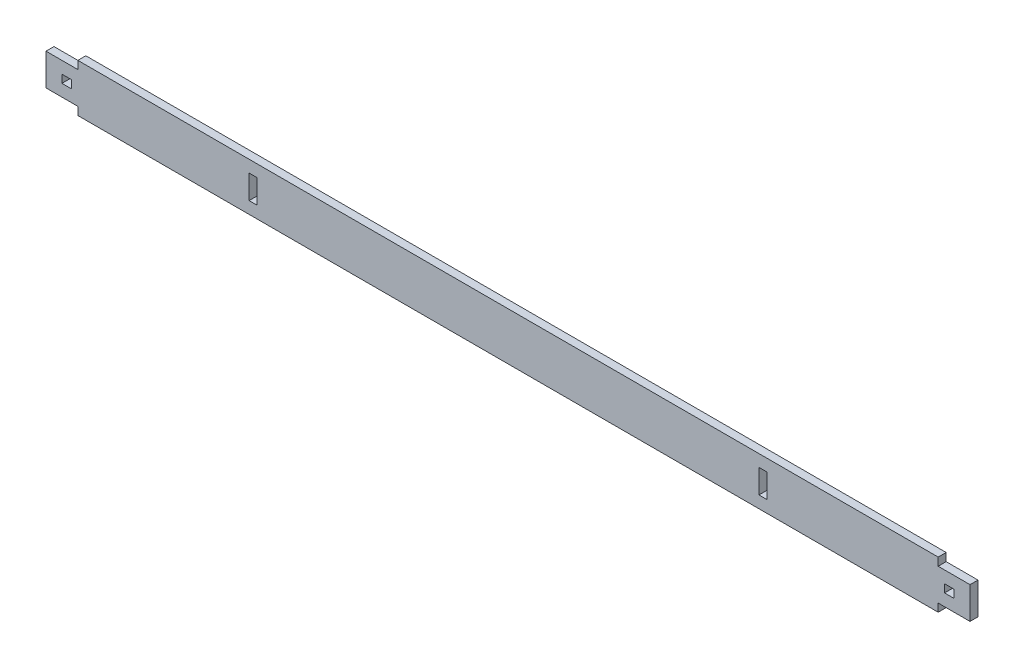
from build123d import *

# Parameters (mm, degrees)
SKETCH1_W           = 685.8
SKETCH1_H           = 38.1
BOSS_EXTRUDE1_DEPTH = 6.35
SKETCH2_W           = 50.8
SKETCH2_H           = 25.4
BOSS_EXTRUDE2_DEPTH = 6.35
SKETCH3_W           = 7.62
SKETCH3_H           = 6.35
CUT_EXTRUDE1_DEPTH  = 7.35
SKETCH4_W           = 6.35
SKETCH4_H           = 19.05
CUT_EXTRUDE2_DEPTH  = 7.35


with BuildPart() as part:
    # Sketch1 → Boss-Extrude1 (new body)
    with BuildSketch(Plane.XY):
        Rectangle(SKETCH1_W, SKETCH1_H)
    extrude(amount=BOSS_EXTRUDE1_DEPTH)

    # Sketch2 → Boss-Extrude2 (add)
    with BuildSketch(Plane.XY.offset(6.35)):
        with Locations((-342.9, 0)):
            Rectangle(SKETCH2_W, SKETCH2_H)
    boss_extrude2 = extrude(amount=-BOSS_EXTRUDE2_DEPTH)

    # Sketch3 → Cut-Extrude1 (cut, through all)
    with BuildSketch(Plane.XY.offset(6.35)):
        with Locations((-351.79, 0)):
            Rectangle(SKETCH3_W, SKETCH3_H)
    cut_extrude1 = extrude(amount=-CUT_EXTRUDE1_DEPTH, mode=Mode.SUBTRACT)

    # Mirror1: Boss-Extrude2, Cut-Extrude1 across plane
    add(boss_extrude2.mirror(Plane(origin=(0, 0, 0), x_dir=(0, 0, 1), z_dir=(1, 0, 0))))
    add(cut_extrude1.mirror(Plane(origin=(0, 0, 0), x_dir=(0, 0, 1), z_dir=(1, 0, 0))), mode=Mode.SUBTRACT)

    # Sketch4 → Cut-Extrude2 (cut, through all)
    with BuildSketch(Plane.XY.offset(6.35)):
        with Locations((-203.2, 0)):
            Rectangle(SKETCH4_W, SKETCH4_H)
    cut_extrude2 = extrude(amount=-CUT_EXTRUDE2_DEPTH, mode=Mode.SUBTRACT)

    # Mirror2: Cut-Extrude2 across plane
    add(cut_extrude2.mirror(Plane(origin=(0, 0, 0), x_dir=(0, 0, 1), z_dir=(1, 0, 0))), mode=Mode.SUBTRACT)


solid = part.part
